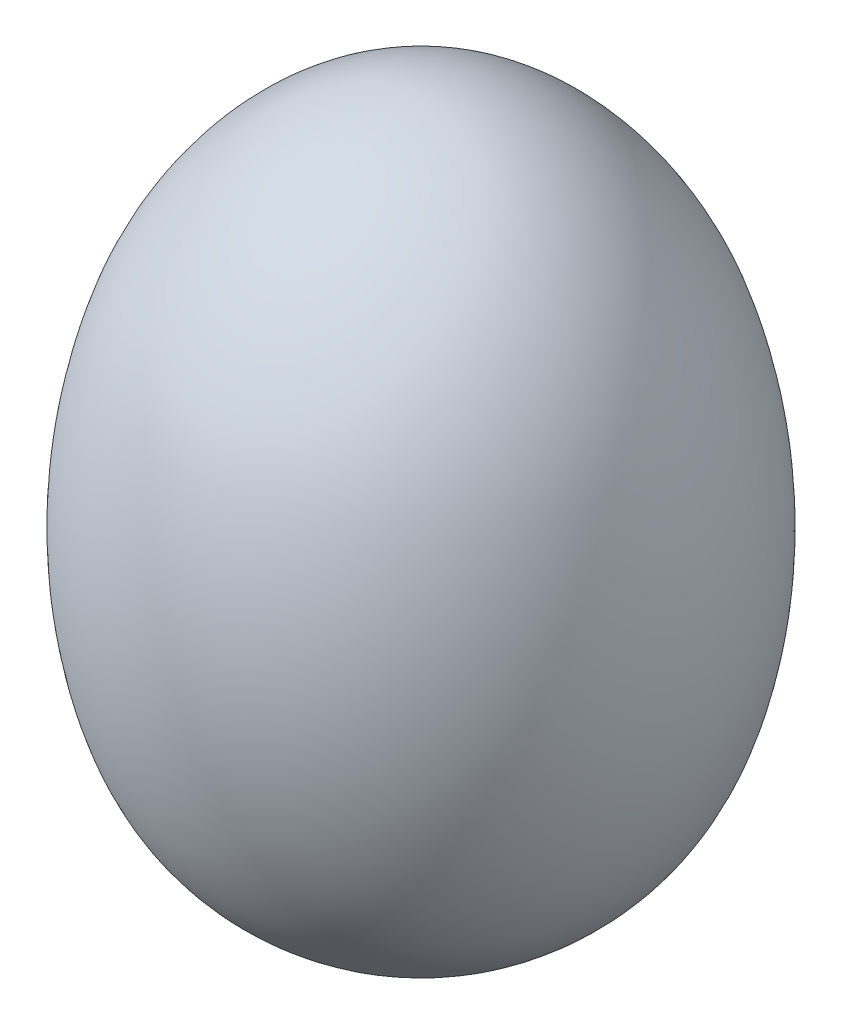
from build123d import *


with BuildPart() as part:
    # Sketch1 → Revolve1 (revolve)
    with BuildSketch(Plane.XY):
        with BuildLine():
            Line((0, 58.24206471), (0, 0))
            add(Edge.make_bspline(
                [(0, 0), (-6.804351107, 0.178148045), (-16.485079004, 5.771771968), (-22.527461702, 22.423776389), (-21.844245478, 34.338431418), (-16.62715892, 49.990104663), (-8.988567863, 58.202305337), (0, 58.24206471)],
                knots=[0, 0, 0, 0, 0.246780737, 0.376033953, 0.652336077, 0.673976772, 1, 1, 1, 1], degree=3))
        make_face()
    revolve(axis=Axis((0, 58.24206471, 0), (0, -1, 0)))


solid = part.part
